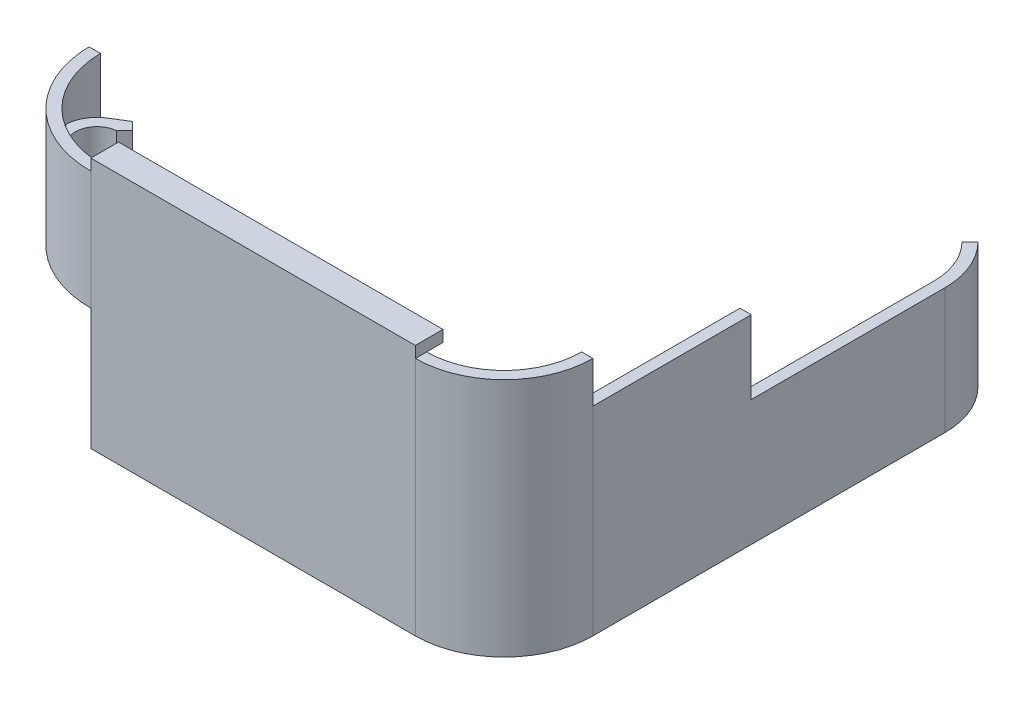
from build123d import *

# Parameters (mm, degrees)
EXTRUDE_THIN1_DEPTH = 53.975
BOSS_EXTRUDE1_START = 27.94
BOSS_EXTRUDE1_DEPTH = 19.05
BOSS_EXTRUDE2_DEPTH = 28.194
SKETCH12_W          = 34.867415814
SKETCH12_H          = 30.773507234
CUT_EXTRUDE1_DEPTH  = 27.000736901
SKETCH13_W          = 2.54
SKETCH13_H          = 35.56
BOSS_EXTRUDE3_DEPTH = 16.51
SKETCH14_W          = 72.898
SKETCH14_H          = 6.223180908
BOSS_EXTRUDE4_DEPTH = 2.54


with BuildPart() as part:
    # Sketch8 → Extrude-Thin1 (new body)
    with BuildSketch(Plane(origin=(0, 0, 0), x_dir=(1, 0, 0), z_dir=(0, 1, 0))):
        with BuildLine():
            ThreePointArc((-21.840673053, -0.381230366), (-15.310661969, -15.580242811), (0, -21.844))
            Line((0, -21.844), (72.898, -21.844))
            ThreePointArc((72.898, -21.844), (85.209931142, -16.744231142), (90.3097, -4.4323))
            Line((90.3097, -4.4323), (92.8497, -4.4323))
            ThreePointArc((92.8497, -4.4323), (87.005982366, -18.540282366), (72.898, -24.384))
            Line((72.898, -24.384), (0, -24.384))
            ThreePointArc((0, -24.384), (-17.090971501, -17.391898952), (-24.380286199, -0.425559479))
            Line((-24.380286199, -0.425559479), (-21.840673053, -0.381230366))
        make_face()
    extrude(amount=EXTRUDE_THIN1_DEPTH)

    # Sketch10 → Boss-Extrude1 (add)
    with BuildSketch(Plane(origin=(0, 0, 0), x_dir=(1, 0, 0), z_dir=(0, 1, 0)).offset(BOSS_EXTRUDE1_START)):
        with BuildLine():
            Line((-6.641231784, -11.936352934), (-4.843541474, -10.138662625))
            Line((-4.843541474, -10.138662625), (-3.045851165, -11.936352934))
            Line((-3.045851165, -11.936352934), (-5.383859486, -15.696211745))
            ThreePointArc((-5.383859486, -15.696211745), (-7.807213542, -17.931410627), (-10.959862847, -18.895548216))
            ThreePointArc((-10.959862847, -18.895548216), (-15.446040528, -15.446040528), (-18.895548216, -10.959862847))
            ThreePointArc((-18.895548216, -10.959862847), (-17.931410627, -7.807213542), (-15.696211745, -5.383859486))
            Line((-15.696211745, -5.383859486), (-11.936352934, -3.045851165))
            Line((-11.936352934, -3.045851165), (-10.138662625, -4.843541474))
            Line((-10.138662625, -4.843541474), (-11.936352934, -6.641231784))
            ThreePointArc((-11.936352934, -6.641231784), (-14.946738288, -14.946738288), (-6.641231784, -11.936352934))
        make_face()
    extrude(amount=BOSS_EXTRUDE1_DEPTH)

    # Sketch11 → Boss-Extrude2 (add)
    with BuildSketch(Plane(origin=(0, 0, 0), x_dir=(1, 0, 0), z_dir=(0, 1, 0))):
        with BuildLine():
            Line((90.3097, -4.4323), (92.8497, -4.4323))
            Line((92.8497, -4.4323), (92.8497, 74.676))
            ThreePointArc((92.8497, 74.676), (91.491251092, 81.505383841), (87.622715901, 87.295055901))
            Line((87.622715901, 87.295055901), (85.826664677, 85.499004677))
            ThreePointArc((85.826664677, 85.499004677), (89.14459708, 80.533367923), (90.3097, 74.676))
            Line((90.3097, 74.676), (90.3097, -4.4323))
        make_face()
    extrude(amount=BOSS_EXTRUDE2_DEPTH)

    # Sketch12 → Cut-Extrude1 (cut, through all)
    with BuildSketch(Plane(origin=(0, 0, 0), x_dir=(-0.999847695, 0, 0.017452406), z_dir=(-0.017452406, 0, -0.999847695))):
        with Locations((17.814938273, 11.918246383)):
            Rectangle(SKETCH12_W, SKETCH12_H)
    extrude(amount=-CUT_EXTRUDE1_DEPTH, mode=Mode.SUBTRACT)

    # Sketch13 → Boss-Extrude3 (add)
    with BuildSketch(Plane(origin=(0, 28.194, 0), x_dir=(1, 0, 0), z_dir=(0, 1, 0))):
        with Locations((91.5797, 13.3477)):
            Rectangle(SKETCH13_W, SKETCH13_H)
    extrude(amount=BOSS_EXTRUDE3_DEPTH)

    # Sketch14 → Boss-Extrude4 (add)
    with BuildSketch(Plane(origin=(0, 53.975, 0), x_dir=(1, 0, 0), z_dir=(0, 1, 0))):
        with Locations((36.449, -21.272409546)):
            Rectangle(SKETCH14_W, SKETCH14_H)
    extrude(amount=BOSS_EXTRUDE4_DEPTH)


solid = part.part
